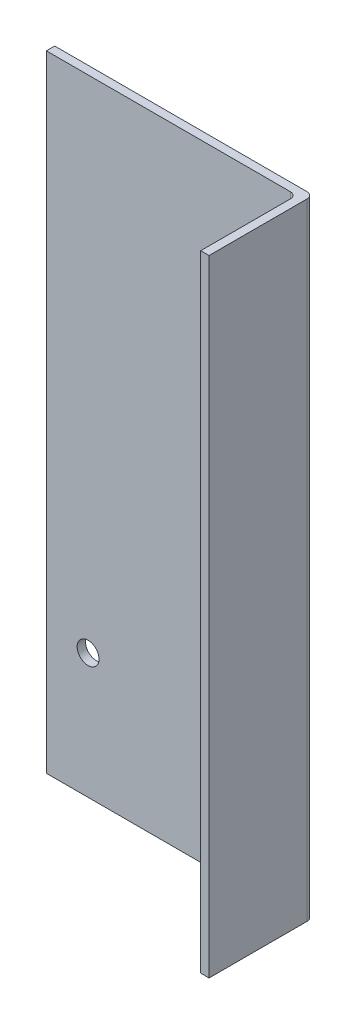
from build123d import *

# Parameters (mm, degrees)
SKETCH1_W        = 120
SKETCH1_H        = 4
EXTRUDE_2_DEPTH  = 300
FILLET_2_R       = 3
HOLES_LEFT_REACH = 6
SKETCH3_R        = 5.25


with BuildPart() as part:
    # Sketch1 → Extrude 2 (new body)
    with BuildSketch(Plane(origin=(0, 0, 0), x_dir=(1, 0, 0), z_dir=(0, 1, 0))):
        Polygon((64, 2), (60, 2), (60, -2), (60, -48), (64, -48), align=None)
        Rectangle(SKETCH1_W, SKETCH1_H)
    extrude(amount=EXTRUDE_2_DEPTH)

    # Fillet 2
    fillet_2_edges = [part.edges().sort_by_distance(p)[0] for p in [
        (64, 150, -2),
        (60, 150, 2),
    ]]
    fillet(fillet_2_edges, radius=FILLET_2_R)

    # Sketch3 → Holes left (cut, up to next)
    with BuildSketch(Plane.XY.offset(2), mode=Mode.PRIVATE) as holes_left_sk1:
        with Locations((-40, 60)):
            Circle(SKETCH3_R)
    holes_left_tool1 = extrude(holes_left_sk1.sketch, amount=-HOLES_LEFT_REACH, mode=Mode.PRIVATE) & part.part
    add(holes_left_tool1.solids().sort_by_distance((-40, 60, 2))[0], mode=Mode.SUBTRACT)
    # Sketch3 → Holes left (cut, up to next)
    with BuildSketch(Plane.XY.offset(2), mode=Mode.PRIVATE) as holes_left_sk2:
        with Locations((40, 60)):
            Circle(SKETCH3_R)
    holes_left_tool2 = extrude(holes_left_sk2.sketch, amount=-HOLES_LEFT_REACH, mode=Mode.PRIVATE) & part.part
    add(holes_left_tool2.solids().sort_by_distance((40, 60, 2))[0], mode=Mode.SUBTRACT)


solid = part.part
